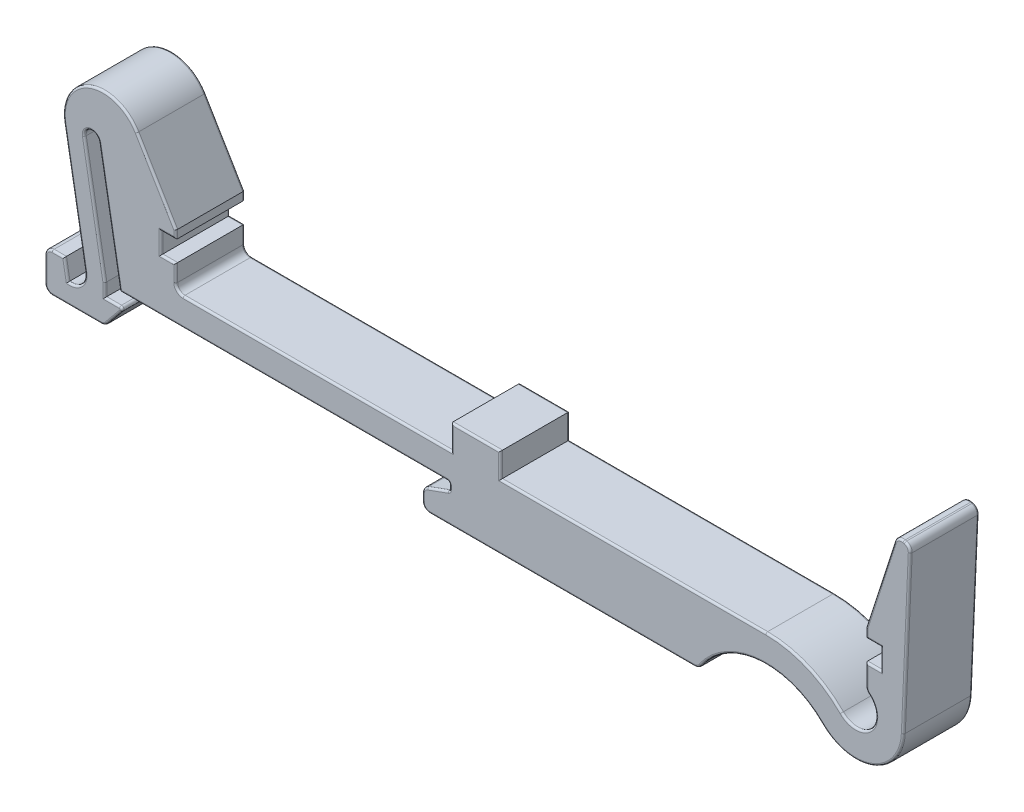
from build123d import *

# Parameters (mm, degrees)
BOSS_EXTRUDE1_DEPTH = 7
SKETCH2_W           = 5
SKETCH2_H           = 2.50000041
BOSS_EXTRUDE2_DEPTH = 7
FILLET1_R           = 0.2


with BuildPart() as part:
    # Sketch1 → Boss-Extrude1 (new body)
    with BuildSketch(Plane.XY):
        with BuildLine():
            Line((-6.796971951, 0.200000009), (-8.046971806, 0.200000009))
            ThreePointArc((-8.046971806, 0.200000009), (-8.577301897, -0.019669907), (-8.796971813, -0.549999997))
            Line((-8.796971813, -0.549999997), (-8.796971813, -3.049999941))
            ThreePointArc((-8.796971813, -3.049999941), (-8.577301863, -3.580330114), (-8.04697169, -3.800000064))
            Line((-8.04697169, -3.800000064), (-3.076388382, -3.800000064))
            ThreePointArc((-3.076388382, -3.800000064), (-2.755560204, -3.727915451), (-2.496403431, -3.525518122))
            Line((-2.496403431, -3.525518122), (-1.006671701, -1.708505965))
            ThreePointArc((-1.006671701, -1.708505965), (-0.974028244, -1.443057251), (-1.200000009, -1.300000004))
            Line((-1.200000009, -1.300000004), (-2.700000009, -1.300000004))
            Line((-2.700000009, -1.300000004), (-2.700000009, 0))
            Line((-2.700000009, 0), (-4.783778274, 11.817692779))
            ThreePointArc((-4.783778274, 11.817692779), (-4.175408541, 12.686534821), (-3.306566503, 12.078165082))
            Line((-3.306566503, 12.078165082), (-1.176860123, 0))
            Line((-1.176860123, 0), (32.050001657, 0))
            ThreePointArc((32.050001657, 0), (32.226778361, -0.073223308), (32.300001669, -0.250000012))
            Line((32.300001669, -0.250000012), (32.300001669, -0.624949703))
            ThreePointArc((32.300001669, -0.624949703), (32.254789965, -0.768342863), (32.135507751, -0.859871274))
            Line((32.135507751, -0.859871274), (30.043484811, -1.621304491))
            ThreePointArc((30.043484811, -1.621304491), (29.685635823, -1.895891523), (29.549999821, -2.326073823))
            Line((29.549999821, -2.326073823), (29.549999821, -3.050917992))
            ThreePointArc((29.549999821, -3.050917992), (29.769669771, -3.581248165), (30.299999944, -3.800918115))
            Line((30.299999944, -3.800918115), (57.194996393, -3.800918115))
            ThreePointArc((57.194996393, -3.800918115), (57.543571915, -3.714992841), (57.812276995, -3.476905404))
            ThreePointArc((57.812276995, -3.476905404), (63.719050379, -0.032015959), (70.143494523, -2.373757306))
            ThreePointArc((70.143494523, -2.373757306), (75.323050481, -3.474080996), (78.409068328, 0.828825695))
            Line((78.409068328, 0.828825695), (79.111095117, 17.069915141))
            ThreePointArc((79.111095117, 17.069915141), (78.966532799, 17.545918646), (78.555911547, 17.826752737))
            Line((78.555911547, 17.826752737), (78.411756553, 17.865380473))
            ThreePointArc((78.411756553, 17.865380473), (77.859750272, 17.799755092), (77.504965978, 17.371799802))
            Line((77.504965978, 17.371799802), (74.599999702, 8.366627088))
            Line((74.599999702, 8.366627088), (74.599999702, 7.399995259))
            Line((74.599999702, 7.399995259), (76.099999017, 7.399995259))
            Line((76.099999017, 7.399995259), (76.099999017, 5.30000031))
            Line((76.099999017, 5.30000031), (74.599999702, 5.30000031))
            Line((74.599999702, 5.30000031), (74.599999702, 3.188544419))
            ThreePointArc((74.599999702, 3.188544419), (74.671562448, 2.868821121), (74.872594094, 2.610111842))
            ThreePointArc((74.872594094, 2.610111842), (75.081559607, -0.335608674), (72.129130131, -0.399609737))
            ThreePointArc((72.129130131, -0.399609737), (68.602075904, 1.968208055), (64.436167246, 2.7999999))
            Line((64.436167246, 2.7999999), (5.249999929, 2.7999999))
            ThreePointArc((5.249999929, 2.7999999), (4.719669756, 3.01966985), (4.499999806, 3.550000023))
            Line((4.499999806, 3.550000023), (4.499999806, 5.30000031))
            Line((4.499999806, 5.30000031), (3.000000026, 5.30000031))
            Line((3.000000026, 5.30000031), (3.000000026, 7.400000002))
            Line((3.000000026, 7.400000002), (4.499999806, 7.400000002))
            Line((4.499999806, 7.400000002), (4.499999806, 8.227101527))
            Line((4.499999806, 8.227101527), (0.555638873, 14.834694274))
            ThreePointArc((0.555638873, 14.834694274), (-4.301694259, 16.542742916), (-6.859881826, 12.074321304))
            Line((-6.859881826, 12.074321304), (-4.730853096, 0))
            ThreePointArc((-4.730853096, 0), (-5.133070065, -1.332664481), (-6.44431781, -1.799999969))
            Line((-6.44431781, -1.799999969), (-6.796971951, 0.200000009))
        make_face()
    extrude(amount=BOSS_EXTRUDE1_DEPTH)

    # Sketch2 → Boss-Extrude2 (add)
    with BuildSketch(Plane.XY):
        with Locations((35.000000026, 4.050000105)):
            Rectangle(SKETCH2_W, SKETCH2_H)
    extrude(amount=BOSS_EXTRUDE2_DEPTH)

    # Fillet1
    fillet1_edges = [part.edges().sort_by_distance(p)[0] for p in [
        (-7.421971879, 0.200000009, 0),
        (-8.577301897, -0.019669907, 0),
        (-8.796971813, -1.799999969, 0),
        (-8.577301863, -3.580330114, 0),
        (-5.561680036, -3.800000064, 0),
        (-2.755560204, -3.727915451, 0),
        (-1.751537566, -2.617012044, 0),
        (-0.974028244, -1.443057251, 0),
        (-1.950000009, -1.300000004, 0),
        (-2.700000009, -0.650000002, 0),
        (-3.741889142, 5.90884639, 0),
        (-4.175408541, 12.686534821, 0),
        (-2.241713313, 6.039082541, 0),
        (15.436570767, 0, 0),
        (32.226778361, -0.073223308, 0),
        (32.300001669, -0.437474857, 0),
        (32.254789965, -0.768342863, 0),
        (31.089496281, -1.240587883, 0),
        (29.685635823, -1.895891523, 0),
        (29.549999821, -2.688495908, 0),
        (29.769669771, -3.581248165, 0),
        (43.747498168, -3.800918115, 0),
        (57.543571915, -3.714992841, 0),
        (63.719050379, -0.032015959, 0),
        (75.323050481, -3.474080996, 0),
        (78.760081723, 8.949370418, 0),
        (78.966532799, 17.545918646, 0),
        (78.48383405, 17.846066605, 0),
        (77.859750272, 17.799755092, 0),
        (76.05248284, 12.869213445, 0),
        (74.599999702, 7.883311173, 0),
        (75.349999359, 7.399995259, 0),
        (76.099999017, 6.349997785, 0),
        (75.349999359, 5.30000031, 0),
        (74.599999702, 4.244272364, 0),
        (74.671562448, 2.868821121, 0),
        (75.081559607, -0.335608674, 0),
        (68.602075904, 1.968208055, 0),
        (18.874999978, 2.7999999, 0),
        (50.968083636, 2.7999999, 0),
        (4.719669756, 3.01966985, 0),
        (4.499999806, 4.425000167, 0),
        (3.749999916, 5.30000031, 0),
        (3.000000026, 6.350000156, 0),
        (3.749999916, 7.400000002, 0),
        (4.499999806, 7.813550765, 0),
        (2.52781934, 11.5308979, 0),
        (-4.301694259, 16.542742916, 0),
        (-5.795367461, 6.037160652, 0),
        (-5.133070065, -1.332664481, 0),
        (-6.62064488, -0.79999998, 0),
        (-5.133070065, -1.332664481, 7),
        (-5.795367461, 6.037160652, 7),
        (-4.301694259, 16.542742916, 7),
        (2.52781934, 11.5308979, 7),
        (4.499999806, 7.813550765, 7),
        (3.749999916, 7.400000002, 7),
        (3.000000026, 6.350000156, 7),
        (3.749999916, 5.30000031, 7),
        (4.499999806, 4.425000167, 7),
        (4.719669756, 3.01966985, 7),
        (50.968083636, 2.7999999, 7),
        (18.874999978, 2.7999999, 7),
        (68.602075904, 1.968208055, 7),
        (75.081559607, -0.335608674, 7),
        (74.671562448, 2.868821121, 7),
        (74.599999702, 4.244272364, 7),
        (75.349999359, 5.30000031, 7),
        (76.099999017, 6.349997785, 7),
        (75.349999359, 7.399995259, 7),
        (74.599999702, 7.883311173, 7),
        (76.05248284, 12.869213445, 7),
        (77.859750272, 17.799755092, 7),
        (78.48383405, 17.846066605, 7),
        (78.966532799, 17.545918646, 7),
        (78.760081723, 8.949370418, 7),
        (75.323050481, -3.474080996, 7),
        (63.719050379, -0.032015959, 7),
        (57.543571915, -3.714992841, 7),
        (43.747498168, -3.800918115, 7),
        (29.769669771, -3.581248165, 7),
        (29.549999821, -2.688495908, 7),
        (29.685635823, -1.895891523, 7),
        (31.089496281, -1.240587883, 7),
        (32.254789965, -0.768342863, 7),
        (32.300001669, -0.437474857, 7),
        (32.226778361, -0.073223308, 7),
        (15.436570767, 0, 7),
        (-2.241713313, 6.039082541, 7),
        (-4.175408541, 12.686534821, 7),
        (-3.741889142, 5.90884639, 7),
        (-2.700000009, -0.650000002, 7),
        (-1.950000009, -1.300000004, 7),
        (-0.974028244, -1.443057251, 7),
        (-1.751537566, -2.617012044, 7),
        (-2.755560204, -3.727915451, 7),
        (-5.561680036, -3.800000064, 7),
        (-8.577301863, -3.580330114, 7),
        (-8.796971813, -1.799999969, 7),
        (-8.577301897, -0.019669907, 7),
        (-7.421971879, 0.200000009, 7),
        (-6.62064488, -0.79999998, 7),
        (37.500000026, 4.050000105, 7),
        (37.500000026, 4.050000105, 0),
        (35.000000026, 5.30000031, 7),
        (35.000000026, 5.30000031, 0),
        (32.500000026, 4.050000105, 7),
        (32.500000026, 4.050000105, 0),
    ]]
    fillet(fillet1_edges, radius=FILLET1_R)


solid = part.part
